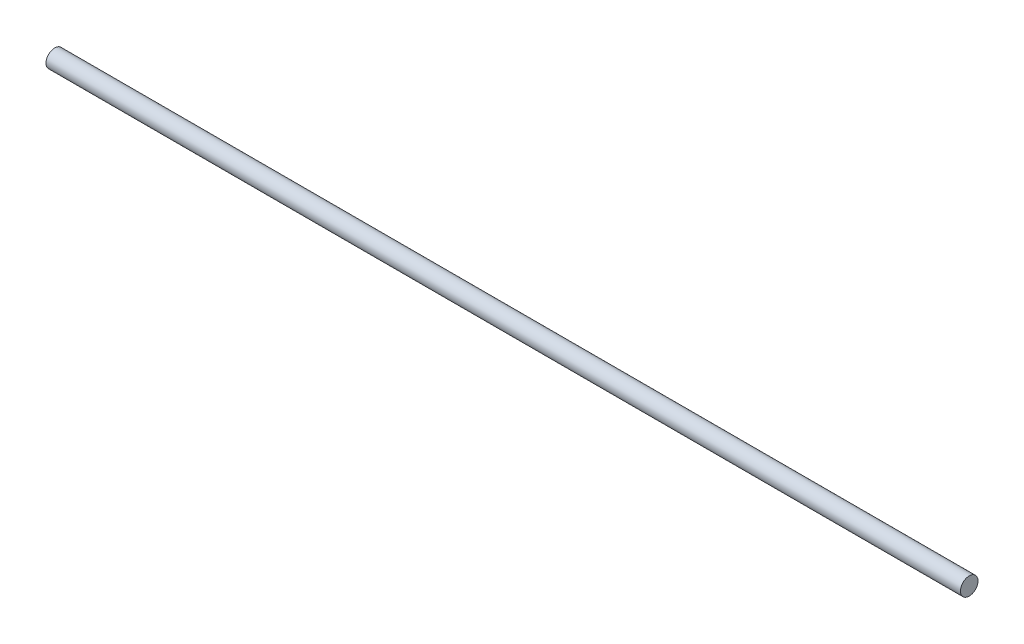
from build123d import *

# Parameters (mm, degrees)
SKETCH1_R           = 4
BOSS_EXTRUDE1_DEPTH = 416.75


with BuildPart() as part:
    # Sketch1 → Boss-Extrude1 (new body)
    with BuildSketch(Plane(origin=(0, 0, 0), x_dir=(0, 0, -1), z_dir=(1, 0, 0))):
        Circle(SKETCH1_R)
    extrude(amount=BOSS_EXTRUDE1_DEPTH)


solid = part.part
